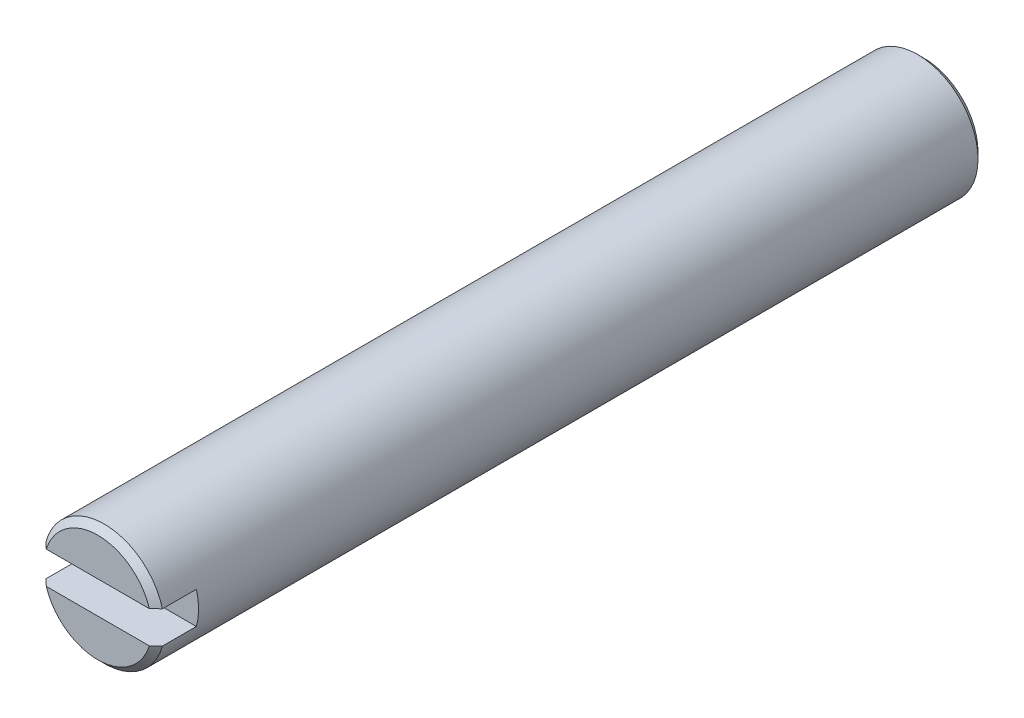
from build123d import *

# Parameters (mm, degrees)
BOSS_EXTRUDE1_DEPTH = 25.63
CUT_EXTRUDE1_DEPTH  = 1.25
CHAMFER1_SIZE       = 0.2
CHAMFER2_SIZE       = 0.2


with BuildPart() as part:
    # Sketch1 → Boss-Extrude1 (new body)
    with BuildSketch(Plane.XY):
        with BuildLine():
            ThreePointArc((1.807104037, 0.5), (0, 1.875), (-1.807104037, 0.5))
            Line((-1.807104037, 0.5), (1.807104037, 0.5))
        make_face()
        with BuildLine():
            Line((1.807104037, -0.5), (-1.807104037, -0.5))
            ThreePointArc((-1.807104037, -0.5), (0, -1.875), (1.807104037, -0.5))
        make_face()
        with BuildLine():
            Line((1.807104037, 0.5), (-1.807104037, 0.5))
            ThreePointArc((-1.807104037, 0.5), (-1.875, 0), (-1.807104037, -0.5))
            Line((-1.807104037, -0.5), (1.807104037, -0.5))
            ThreePointArc((1.807104037, -0.5), (1.857948475, -0.252294402), (1.875, 0))
            ThreePointArc((1.875, 0), (1.857948475, 0.252294402), (1.807104037, 0.5))
        make_face()
    extrude(amount=BOSS_EXTRUDE1_DEPTH)

    # Sketch2 → Cut-Extrude1 (cut)
    with BuildSketch(Plane.XY.offset(25.63)):
        with BuildLine():
            Line((-1.807104037, 0.5), (1.807104037, 0.5))
            ThreePointArc((1.807104037, 0.5), (1.875, 0), (1.807104037, -0.5))
            Line((1.807104037, -0.5), (-1.807104037, -0.5))
            ThreePointArc((-1.807104037, -0.5), (-1.875, 0), (-1.807104037, 0.5))
        make_face()
    extrude(amount=-CUT_EXTRUDE1_DEPTH, mode=Mode.SUBTRACT)

    # Chamfer1
    chamfer1_edges = [part.edges().sort_by_distance(p)[0] for p in [
        (0, 1.875, 25.63),
        (0, -1.875, 25.63),
    ]]
    chamfer(chamfer1_edges, length=CHAMFER1_SIZE)

    # Chamfer2
    chamfer2_edges = [part.edges().sort_by_distance(p)[0] for p in [
        (-1.807104037, 0.5, 0),
    ]]
    chamfer(chamfer2_edges, length=CHAMFER2_SIZE)


solid = part.part
